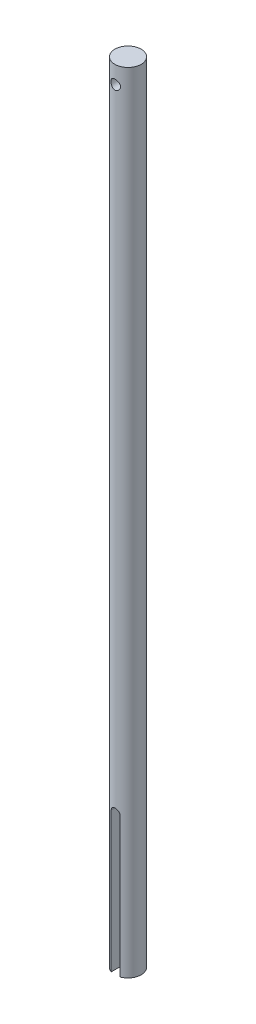
from build123d import *

# Parameters (mm, degrees)
SKETCH1_R               = 4.7625
BOSS_EXTRUDE1_DEPTH     = 285.75
CUT_EXTRUDE1_DEPTH      = 5.7625
CUT_EXTRUDE1_DEPTH_BACK = 5.7625
F_8_32_TAPPED_HOLE1_D   = 3.4544


with BuildPart() as part:
    # Sketch1 → Boss-Extrude1 (new body)
    with BuildSketch(Plane(origin=(0, 0, 0), x_dir=(1, 0, 0), z_dir=(0, 1, 0))):
        Circle(SKETCH1_R)
    extrude(amount=BOSS_EXTRUDE1_DEPTH)

    # Sketch2 → Cut-Extrude1 (cut, two sides)
    with BuildSketch(Plane.XY) as cut_extrude1_sk:
        with BuildLine():
            Line((-1.5875, -50.8), (-1.5875, 50.8))
            ThreePointArc((-1.5875, 50.8), (0, 52.3875), (1.5875, 50.8))
            Line((1.5875, 50.8), (1.5875, -50.8))
            ThreePointArc((1.5875, -50.8), (0, -52.3875), (-1.5875, -50.8))
        make_face()
    extrude(amount=CUT_EXTRUDE1_DEPTH, mode=Mode.SUBTRACT)
    extrude(cut_extrude1_sk.sketch, amount=-CUT_EXTRUDE1_DEPTH_BACK, mode=Mode.SUBTRACT)

    # #8-32 Tapped Hole1 (through all)
    with Locations(Plane(origin=(0, 0, -4.7625), x_dir=(-1, 0, 0), z_dir=(0, 0, -1))):
        with Locations((0, 279.4)):
            Hole(F_8_32_TAPPED_HOLE1_D / 2)


solid = part.part
